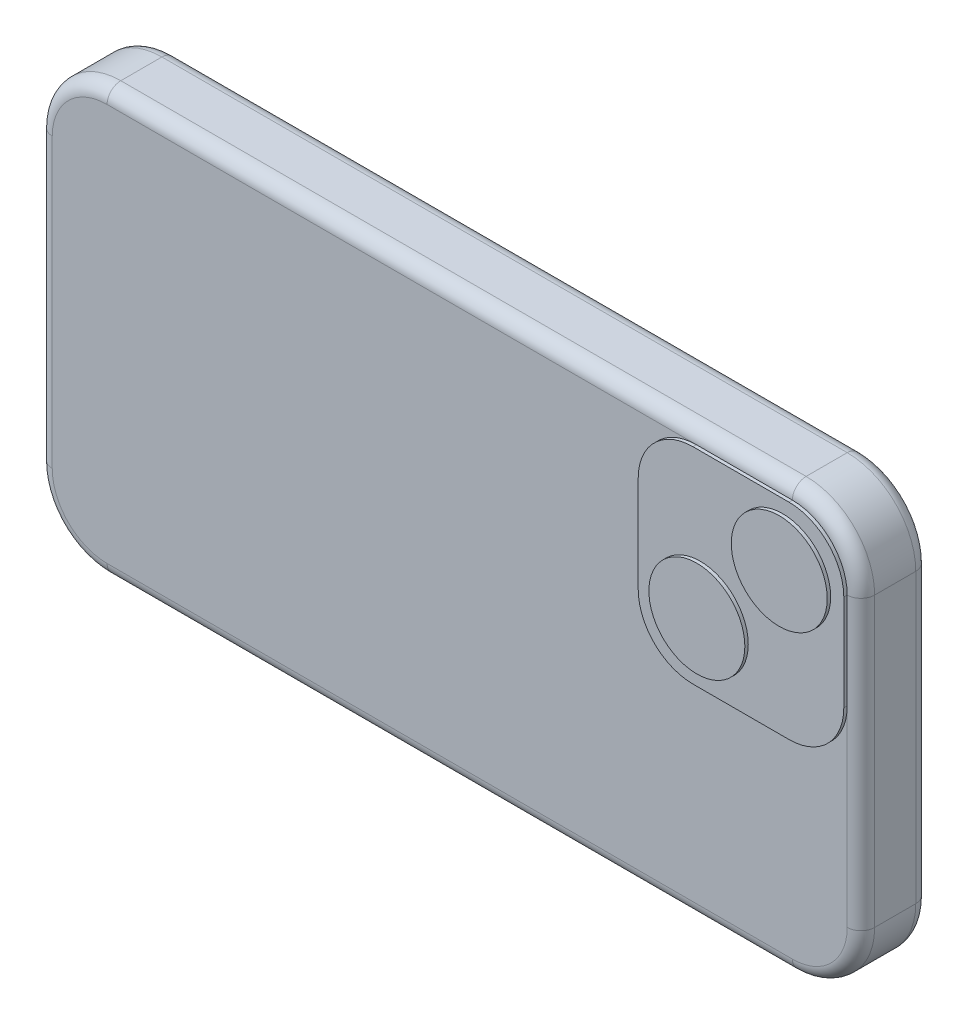
from build123d import *

# Parameters (mm, degrees)
SKETCH1_W           = 152.4
SKETCH1_H           = 78.74
BOSS_EXTRUDE1_DEPTH = 6.35
FILLET1_R           = 12.7
FILLET2_R           = 2.54
BOSS_EXTRUDE2_DEPTH = 0.635
SKETCH3_R           = 8.89
BOSS_EXTRUDE3_DEPTH = 0.635


with BuildPart() as part:
    # Sketch1 → Boss-Extrude1 (new body, symmetric)
    with BuildSketch(Plane.XY):
        Rectangle(SKETCH1_W, SKETCH1_H)
    extrude(amount=BOSS_EXTRUDE1_DEPTH, both=True)

    # Fillet1
    fillet1_edges = [part.edges().sort_by_distance(p)[0] for p in [
        (76.2, -39.37, 0),
        (-76.2, -39.37, 0),
        (-76.2, 39.37, 0),
        (76.2, 39.37, 0),
    ]]
    fillet(fillet1_edges, radius=FILLET1_R)

    # Fillet2
    fillet2_edges = [part.edges().sort_by_distance(p)[0] for p in [
        (0, 39.37, -6.35),
        (0, 39.37, 6.35),
        (76.2, 0, -6.35),
        (0, -39.37, -6.35),
        (-76.2, 0, -6.35),
        (-72.480256121, 35.650256121, -6.35),
        (-72.480256121, -35.650256121, -6.35),
        (72.480256121, -35.650256121, -6.35),
        (72.480256121, 35.650256121, -6.35),
        (76.2, 0, 6.35),
        (-76.2, 0, 6.35),
        (0, -39.37, 6.35),
        (-72.480256121, 35.650256121, 6.35),
        (-72.480256121, -35.650256121, 6.35),
        (72.480256121, -35.650256121, 6.35),
        (72.480256121, 35.650256121, 6.35),
    ]]
    fillet(fillet2_edges, radius=FILLET2_R)

    # Sketch2 → Boss-Extrude2 (add, symmetric)
    with BuildSketch(Plane.XY.offset(6.35)):
        with BuildLine():
            ThreePointArc((73.66, 26.67), (70.684204897, 33.854204897), (63.5, 36.83))
            Line((63.5, 36.83), (45.72, 36.83))
            ThreePointArc((45.72, 36.83), (38.535795103, 33.854204897), (35.56, 26.67))
            Line((35.56, 26.67), (35.56, 8.89))
            ThreePointArc((35.56, 8.89), (38.535795103, 1.705795103), (45.72, -1.27))
            Line((45.72, -1.27), (63.5, -1.27))
            ThreePointArc((63.5, -1.27), (70.684204897, 1.705795103), (73.66, 8.89))
            Line((73.66, 8.89), (73.66, 26.67))
        make_face()
    extrude(amount=BOSS_EXTRUDE2_DEPTH, both=True)

    # Sketch3 → Boss-Extrude3 (add, symmetric)
    with BuildSketch(Plane.XY.offset(6.985)):
        with Locations((62.333473824, 25.503473824)):
            Circle(SKETCH3_R)
        with Locations((47.067038418, 10.237038418)):
            Circle(SKETCH3_R)
    extrude(amount=BOSS_EXTRUDE3_DEPTH, both=True)


solid = part.part
